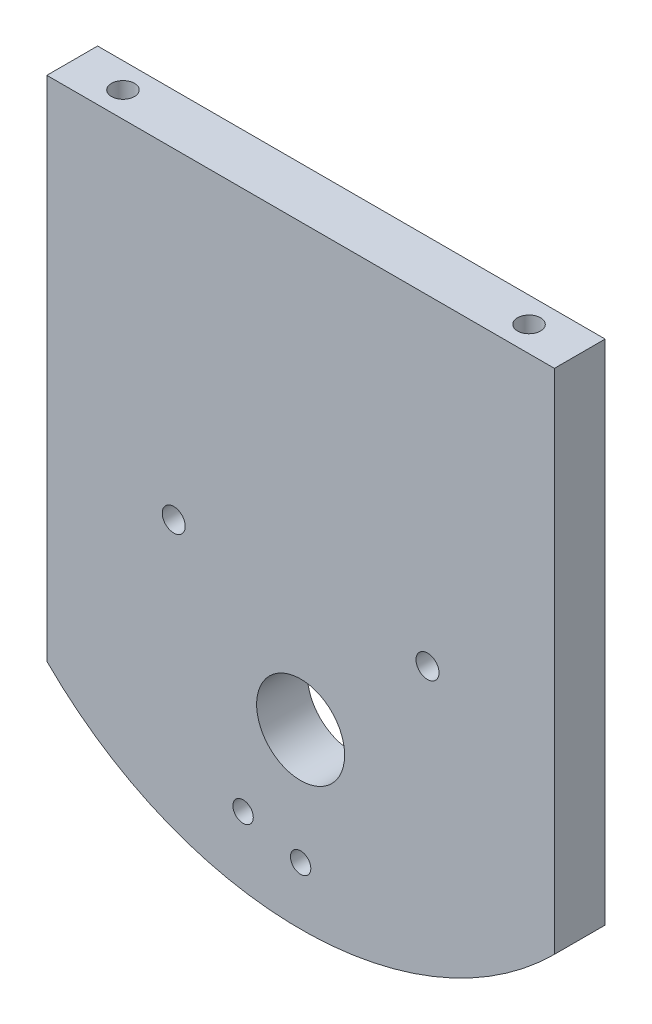
from build123d import *

# Parameters (mm, degrees)
SKETCH2_W                        = 150
SKETCH2_H                        = 90
SKETCH2_H_2                      = 60
BOSS_EXTRUDE1_DEPTH              = 15
SKETCH3_R                        = 13.005
SKETCH3_R_2                      = 3.01
CUT_EXTRUDE1_DEPTH               = 16
TAP_DRILL_FOR_M8X1_25_TAP2_D     = 6.8
TAP_DRILL_FOR_M8X1_25_TAP2_DEPTH = 10
TAP_DRILL_FOR_M8X1_25_TAP2_TIP   = 2.042926105
TAP_DRILL_FOR_M8X1_25_TAP3_D     = 6.8
TAP_DRILL_FOR_M8X1_25_TAP3_DEPTH = 40
TAP_DRILL_FOR_M8X1_25_TAP3_TIP   = 2.042926105


with BuildPart() as part:
    # Sketch2 → Boss-Extrude1 (new body)
    with BuildSketch(Plane.XY):
        Rectangle(SKETCH2_W, SKETCH2_H)
        with Locations((0, -75)):
            Rectangle(SKETCH2_W, SKETCH2_H_2)
        with BuildLine():
            Line((-75, -105), (75, -105))
            ThreePointArc((75, -105), (0, -136.066017178), (-75, -105))
        make_face()
    extrude(amount=BOSS_EXTRUDE1_DEPTH)

    # Sketch3 → Cut-Extrude1 (cut, through all)
    with BuildSketch(Plane.XY.offset(15)):
        with Locations((0, -85)):
            Circle(SKETCH3_R)
        with Locations((-17, -114.444863729)):
            Circle(SKETCH3_R_2)
        with Locations((0, -119)):
            Circle(SKETCH3_R_2)
    extrude(amount=-CUT_EXTRUDE1_DEPTH, mode=Mode.SUBTRACT)

    # Tap Drill for M8x1.25 Tap2
    with Locations(Plane.XY.offset(15)):
        with Locations((-37.5, -50), (37.5, -50)):
            Hole(TAP_DRILL_FOR_M8X1_25_TAP2_D / 2, depth=TAP_DRILL_FOR_M8X1_25_TAP2_DEPTH)
            with Locations((0, 0, -(TAP_DRILL_FOR_M8X1_25_TAP2_DEPTH + TAP_DRILL_FOR_M8X1_25_TAP2_TIP / 2))):  # 118° drill point
                Cone(0, TAP_DRILL_FOR_M8X1_25_TAP2_D / 2, TAP_DRILL_FOR_M8X1_25_TAP2_TIP, mode=Mode.SUBTRACT)

    # Tap Drill for M8x1.25 Tap3
    with Locations(Plane(origin=(0, 45, 0), x_dir=(1, 0, 0), z_dir=(0, 1, 0))):
        with Locations((-60, -7.5), (60, -7.5)):
            Hole(TAP_DRILL_FOR_M8X1_25_TAP3_D / 2, depth=TAP_DRILL_FOR_M8X1_25_TAP3_DEPTH)
            with Locations((0, 0, -(TAP_DRILL_FOR_M8X1_25_TAP3_DEPTH + TAP_DRILL_FOR_M8X1_25_TAP3_TIP / 2))):  # 118° drill point
                Cone(0, TAP_DRILL_FOR_M8X1_25_TAP3_D / 2, TAP_DRILL_FOR_M8X1_25_TAP3_TIP, mode=Mode.SUBTRACT)


solid = part.part
